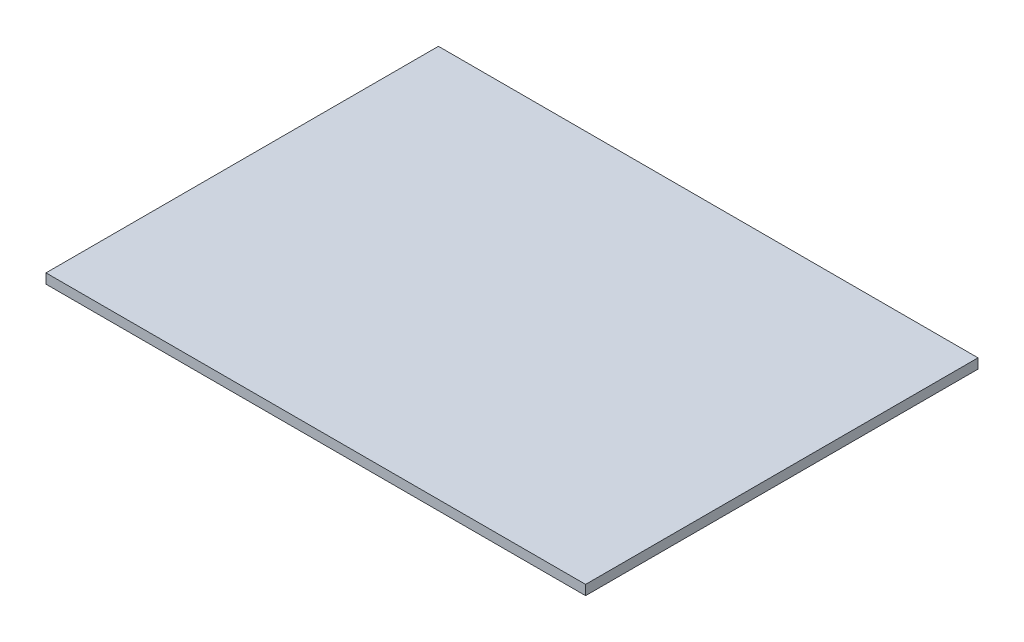
from build123d import *

# Parameters (mm, degrees)
SKETCH1_W           = 825
SKETCH1_H           = 600
BOSS_EXTRUDE1_DEPTH = 15


with BuildPart() as part:
    # Sketch1 → Boss-Extrude1 (new body)
    with BuildSketch(Plane(origin=(0, 0, 0), x_dir=(1, 0, 0), z_dir=(0, 1, 0))):
        with Locations((12.5, 0)):
            Rectangle(SKETCH1_W, SKETCH1_H)
    extrude(amount=BOSS_EXTRUDE1_DEPTH)


solid = part.part
